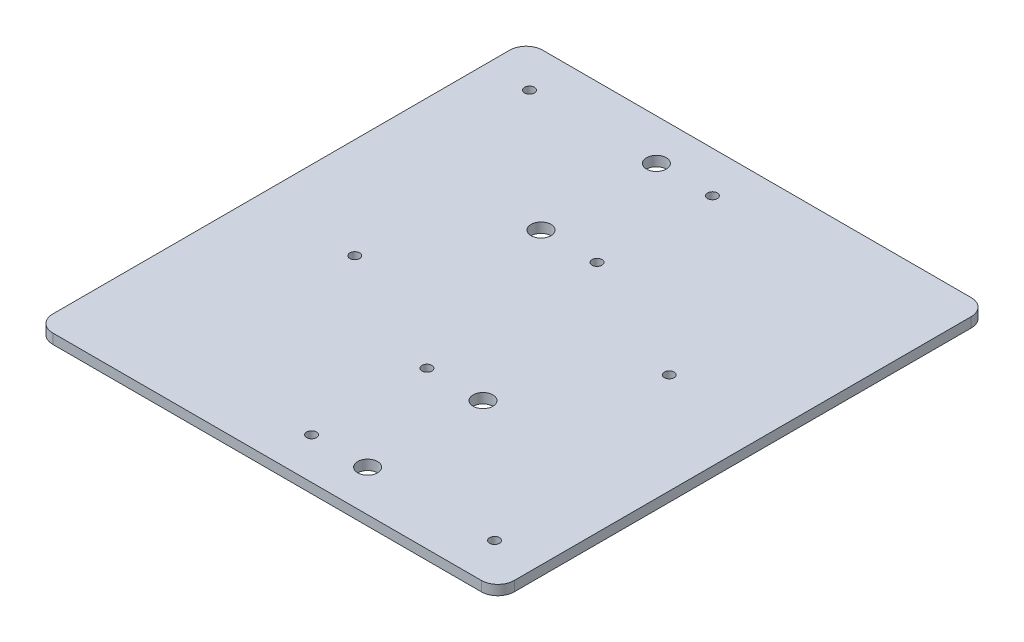
from build123d import *

# Parameters (mm, degrees)
SKETCH1_W           = 140
SKETCH1_H           = 148.6
BOSS_EXTRUDE1_DEPTH = 3
SKETCH2_R           = 3
SKETCH2_R_2         = 1.5
CUT_EXTRUDE1_DEPTH  = 103.124874541
FILLET1_R           = 5
CIRPATTERN1_COUNT   = 2


with BuildPart() as part:
    # Sketch1 → Boss-Extrude1 (new body)
    with BuildSketch(Plane(origin=(0, 0, 0), x_dir=(1, 0, 0), z_dir=(0, 1, 0))):
        Rectangle(SKETCH1_W, SKETCH1_H)
    extrude(amount=BOSS_EXTRUDE1_DEPTH)

    # Sketch2 → Cut-Extrude1 (cut, through all)
    with BuildSketch(Plane(origin=(0, 3, 0), x_dir=(1, 0, 0), z_dir=(0, 1, 0))):
        with Locations((-18, 26.8)):
            Circle(SKETCH2_R)
        with Locations((-18, 61.8)):
            Circle(SKETCH2_R)
        with Locations((-1, 61.8)):
            Circle(SKETCH2_R_2)
        with Locations((-1, 26.8)):
            Circle(SKETCH2_R_2)
        with Locations((-56.5, 61.8)):
            Circle(SKETCH2_R_2)
        with Locations((-39.5, -8.2)):
            Circle(SKETCH2_R_2)
    cut_extrude1 = extrude(amount=-CUT_EXTRUDE1_DEPTH, mode=Mode.SUBTRACT)

    # Fillet1
    fillet1_edges = [part.edges().sort_by_distance(p)[0] for p in [
        (-70, 1.5, -74.3),
        (70, 1.5, -74.3),
        (70, 1.5, 74.3),
        (-70, 1.5, 74.3),
    ]]
    fillet(fillet1_edges, radius=FILLET1_R)

    # CirPattern1: Cut-Extrude1 ×2 about axis
    cirpattern1_axis = Axis((0, -0.15, 0), (0, 1, 0))
    for i in range(1, CIRPATTERN1_COUNT):
        add(cut_extrude1.rotate(cirpattern1_axis, i * 360 / CIRPATTERN1_COUNT), mode=Mode.SUBTRACT)


solid = part.part
